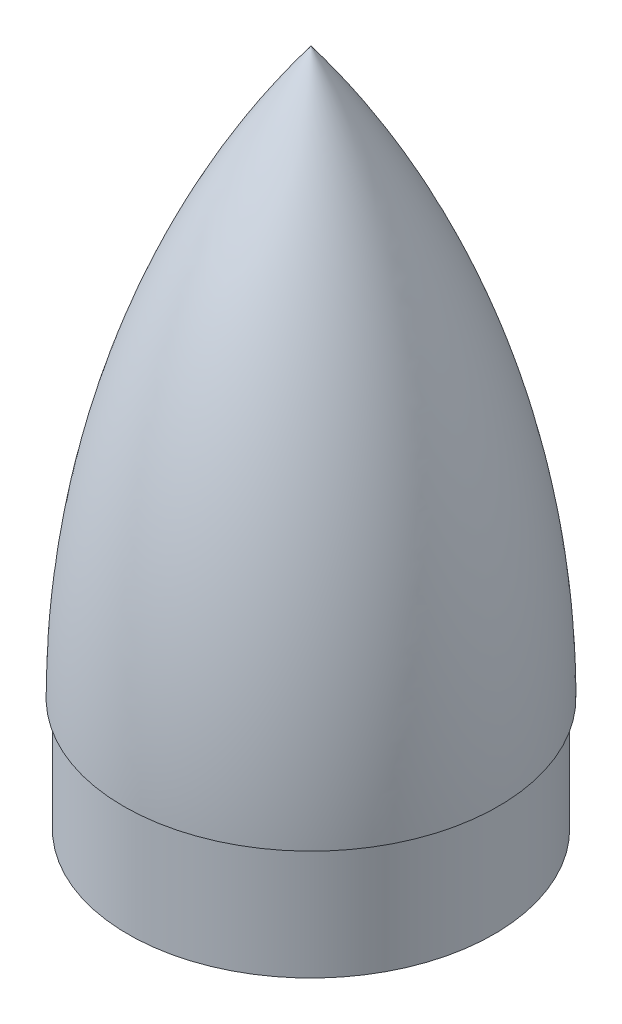
from build123d import *


with BuildPart() as part:
    # Sketch1 → Revolve1 (revolve)
    with BuildSketch(Plane.XY):
        with BuildLine():
            Line((32.385, -20), (32.385, 0))
            Line((32.385, 0), (33.16, 0))
            ThreePointArc((33.16, 0), (24.653840252, 52.677285427), (0, 100))
            Line((0, 100), (0, 85))
            ThreePointArc((0, 85), (20.335803323, 48.772389087), (27.385, 7.82982547))
            Line((27.385, 7.82982547), (27.385, -20))
            Line((27.385, -20), (32.385, -20))
        make_face()
    revolve(axis=Axis((0, 85, 0), (0, 1, 0)))


solid = part.part
